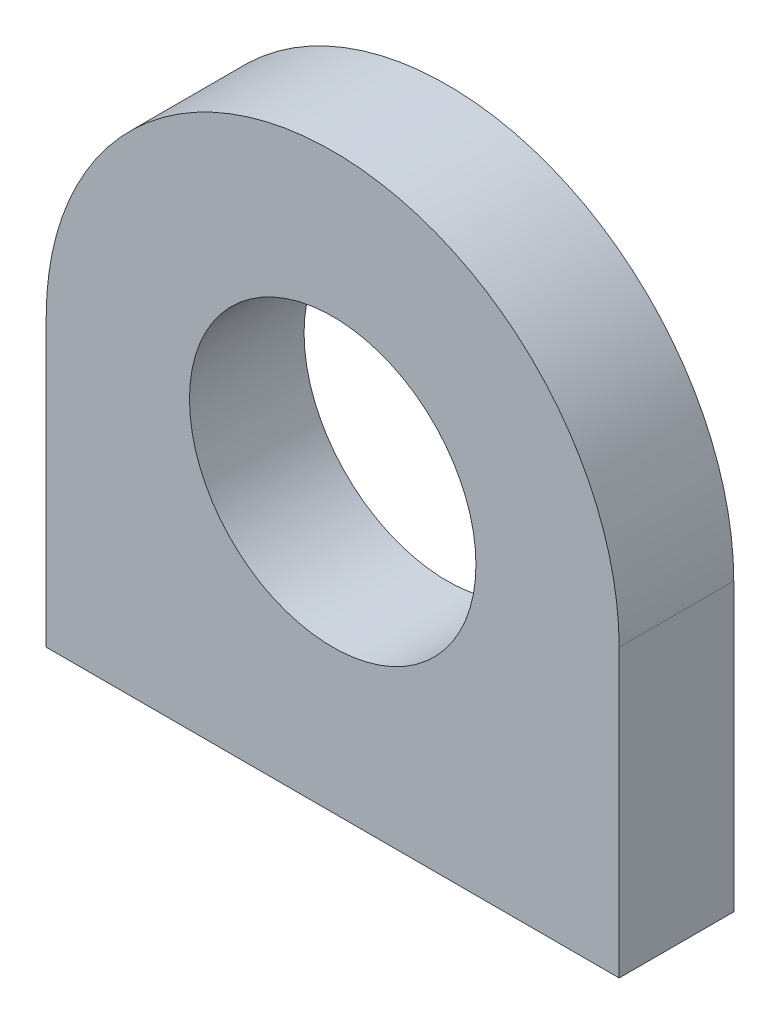
from build123d import *

# Parameters (mm, degrees)
SKETCH1_R           = 5
BOSS_EXTRUDE1_DEPTH = 4
SKETCH2_R           = 1
CUT_EXTRUDE1_DEPTH  = 4


with BuildPart() as part:
    # Sketch1 → Boss-Extrude1 (new body)
    with BuildSketch(Plane.XY):
        with BuildLine():
            Line((-10, -5), (10, -5))
            Line((10, -5), (10, 5))
            ThreePointArc((10, 5), (0, 15), (-10, 5))
            Line((-10, 5), (-10, -5))
        make_face()
        with Locations((0, 5)):
            Circle(SKETCH1_R, mode=Mode.SUBTRACT)
    extrude(amount=BOSS_EXTRUDE1_DEPTH)

    # Sketch2 → Cut-Extrude1 (cut)
    with BuildSketch(Plane.XZ.offset(5)):
        with Locations((-7, 2)):
            Circle(SKETCH2_R)
        with Locations((7, 2)):
            Circle(SKETCH2_R)
    extrude(amount=-CUT_EXTRUDE1_DEPTH, mode=Mode.SUBTRACT)


solid = part.part
